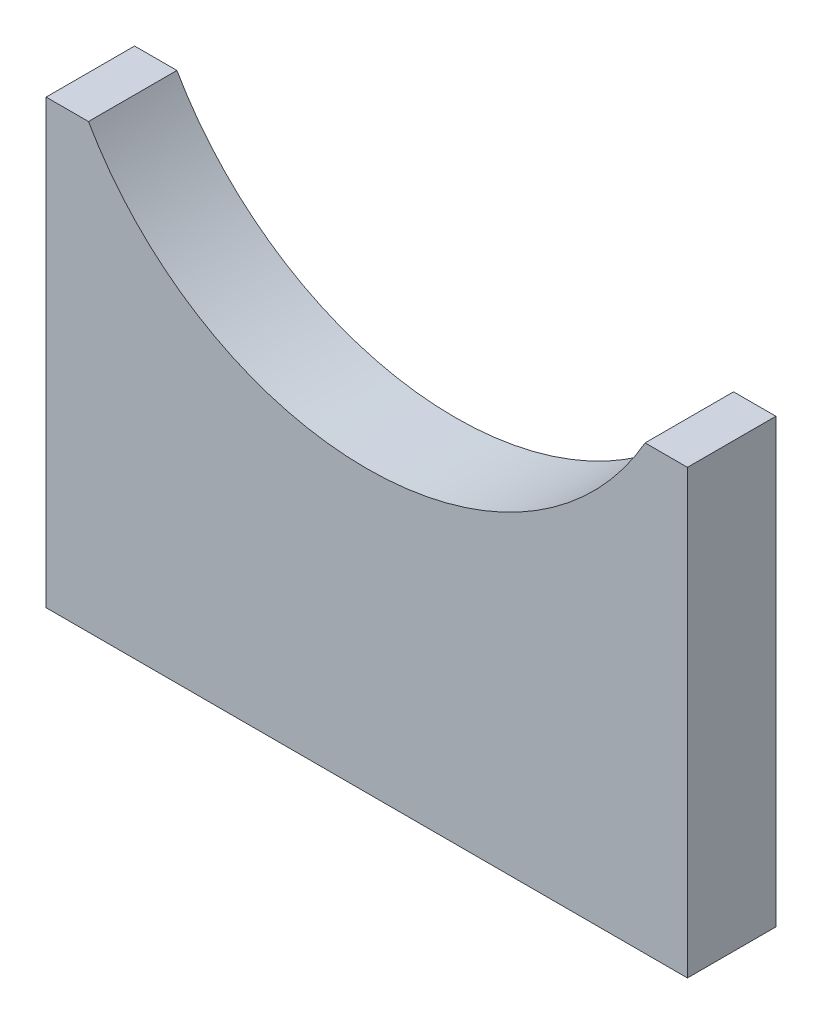
from build123d import *

# Parameters (mm, degrees)
BOSS_EXTRUDE1_DEPTH = 6.35
SKETCH2_R           = 3.3655
CUT_EXTRUDE1_DEPTH  = 12.7


with BuildPart() as part:
    # Sketch1 → Boss-Extrude1 (new body, symmetric)
    with BuildSketch(Plane.XY):
        with BuildLine():
            Line((-46.0375, 63.5), (-39.960878447, 63.5))
            ThreePointArc((-39.960878447, 63.5), (0, 40.3225), (39.960878447, 63.5))
            Line((39.960878447, 63.5), (46.0375, 63.5))
            Line((46.0375, 63.5), (46.0375, 0))
            Line((46.0375, 0), (-46.0375, 0))
            Line((-46.0375, 0), (-46.0375, 63.5))
        make_face()
    extrude(amount=BOSS_EXTRUDE1_DEPTH, both=True)

    # Sketch2 → Cut-Extrude1 (cut)
    with BuildSketch(Plane.XZ):
        with Locations((-38.1, 0)):
            Circle(SKETCH2_R)
        with Locations((38.1, 0)):
            Circle(SKETCH2_R)
    extrude(amount=-CUT_EXTRUDE1_DEPTH, mode=Mode.SUBTRACT)


solid = part.part
